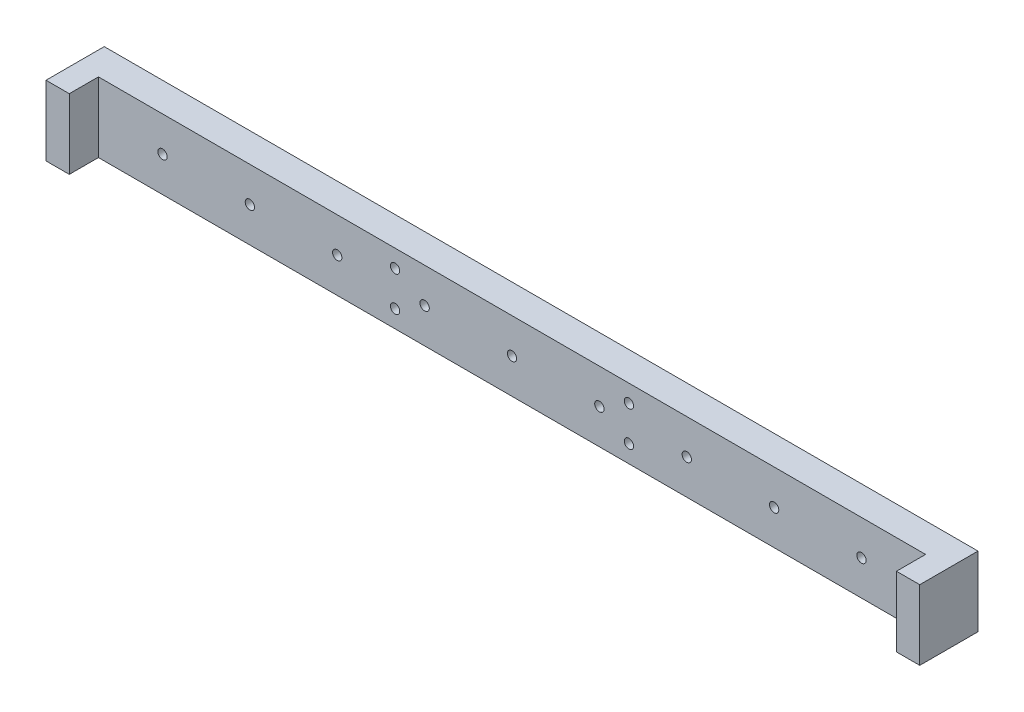
from build123d import *

# Parameters (mm, degrees)
SKETCH_1_W             = 150
SKETCH_1_H             = 12
EXTRUDE_1_DEPTH        = 5
SKETCH_2_W             = 4
SKETCH_2_H             = 12
EXTRUDE_2_DEPTH        = 5
HOLE_WIZARD_M2_2_D     = 1.6
HOLE_WIZARD_M2_2_DEPTH = 5.2
HOLE_WIZARD_M2_2_TIP   = 0.480688495
HOLE_WIZARD_M2_3_D     = 1.6
HOLE_WIZARD_M2_4_D     = 1.6


with BuildPart() as part:
    # 草图1 → 凸台-拉伸1 (new body)
    with BuildSketch(Plane.XY):
        Rectangle(SKETCH_1_W, SKETCH_1_H)
    extrude(amount=EXTRUDE_1_DEPTH)

    # 草图2 → 凸台-拉伸2 (add)
    with BuildSketch(Plane.XY.offset(5)):
        with Locations((-73, 0)):
            Rectangle(SKETCH_2_W, SKETCH_2_H)
    extrude_2 = extrude(amount=EXTRUDE_2_DEPTH)

    # 镜向1: 凸台-拉伸2 across plane
    add(extrude_2.mirror(Plane(origin=(0, 0, 0), x_dir=(0, 0, 1), z_dir=(1, 0, 0))))

    # M2 螺纹孔2
    with Locations(Plane(origin=(0, 0, 0), x_dir=(-1, 0, 0), z_dir=(0, 0, -1))):
        with Locations((-20.075, -3), (-20.075, 3), (20.075, -3), (20.075, 3)):
            Hole(HOLE_WIZARD_M2_2_D / 2, depth=HOLE_WIZARD_M2_2_DEPTH)
            with Locations((0, 0, -(HOLE_WIZARD_M2_2_DEPTH + HOLE_WIZARD_M2_2_TIP / 2))):  # 118° drill point
                Cone(0, HOLE_WIZARD_M2_2_D / 2, HOLE_WIZARD_M2_2_TIP, mode=Mode.SUBTRACT)

    # M2 螺纹孔3 (through all)
    with Locations(Plane(origin=(0, 0, 0), x_dir=(-1, 0, 0), z_dir=(0, 0, -1))):
        with Locations((0, 0)):
            Hole(HOLE_WIZARD_M2_3_D / 2)

    # M2 螺纹孔4 (through all)
    with Locations(Plane.XY.offset(5)):
        with Locations((0, 0), (15, 0), (30, 0), (-30, 0), (-45, 0), (-60, 0), (-15, 0), (45, 0), (60, 0)):
            Hole(HOLE_WIZARD_M2_4_D / 2)


solid = part.part
